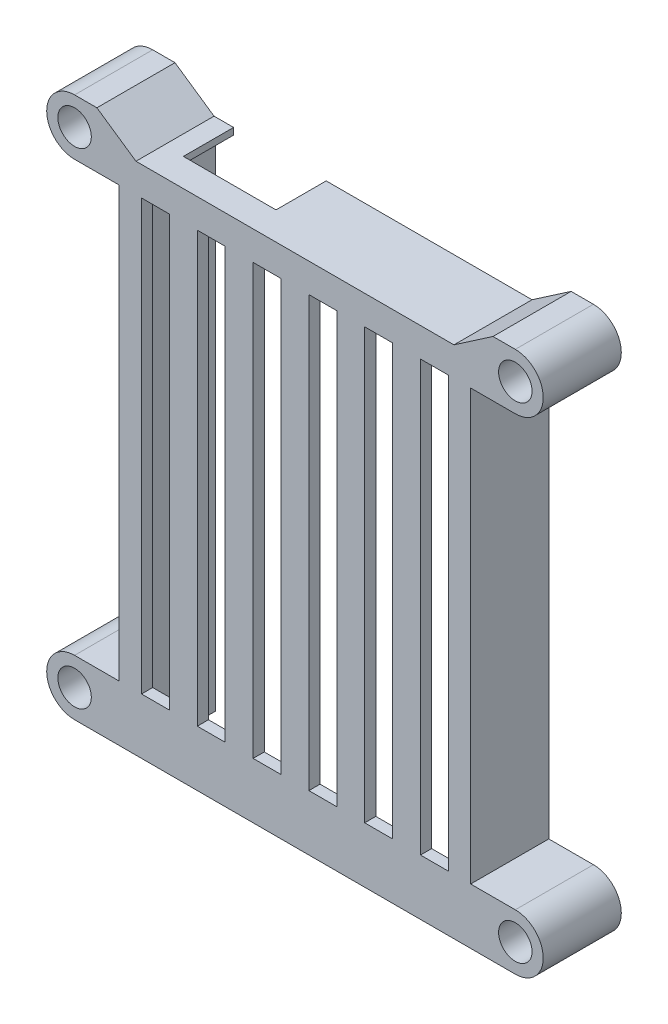
from build123d import *

# Parameters (mm, degrees)
EXTRUDE_1_DEPTH          = 2
EXTRUDE_2_DEPTH          = 12
SKETCH_5_R               = 3
CUT_EXTRUDE_1_DEPTH      = 15
SKETCH_8_W               = 16.6
SKETCH_8_H               = 9
CUT_EXTRUDE_3_DEPTH      = 7
CUT_EXTRUDE_5_DEPTH      = 1
CUT_EXTRUDE_5_DEPTH_BACK = 15
SKETCH_11_W              = 5
SKETCH_11_H              = 77
CUT_EXTRUDE_6_DEPTH      = 2


with BuildPart() as part:
    # 草图1 → 凸台-拉伸1 (new body)
    with BuildSketch(Plane.XY):
        with BuildLine():
            Line((0, 0), (8, 0))
            Line((8, 0), (8, 77))
            Line((8, 77), (0, 77))
            ThreePointArc((0, 77), (-5, 82), (0, 87))
            Line((0, 87), (79, 87))
            ThreePointArc((79, 87), (84, 82), (79, 77))
            Line((79, 77), (71, 77))
            Line((71, 77), (71, 0))
            Line((71, 0), (79, 0))
            ThreePointArc((79, 0), (84, -5), (79, -10))
            Line((79, -10), (71, -10))
            Line((71, -10), (8, -10))
            Line((8, -10), (0, -10))
            ThreePointArc((0, -10), (-5, -5), (0, 0))
        make_face()
    extrude(amount=EXTRUDE_1_DEPTH)

    # 草图4 → 凸台-拉伸2 (add)
    with BuildSketch(Plane(origin=(0, 0, 0), x_dir=(-1, 0, 0), z_dir=(0, 0, -1))):
        with BuildLine():
            Line((-11.3, 81), (-11.3, -10))
            Line((-11.3, -10), (0, -10))
            ThreePointArc((0, -10), (5, -5), (0, 0))
            Line((0, 0), (-8, 0))
            Line((-8, 0), (-8, 77))
            Line((-8, 77), (0, 77))
            ThreePointArc((0, 77), (5, 82), (0, 87))
            Line((0, 87), (-79, 87))
            ThreePointArc((-79, 87), (-84, 82), (-79, 77))
            Line((-79, 77), (-71, 77))
            Line((-71, 77), (-71, 0))
            Line((-71, 0), (-79, 0))
            ThreePointArc((-79, 0), (-84, -5), (-79, -10))
            Line((-79, -10), (-67.7, -10))
            Line((-67.7, -10), (-67.7, 81))
            Line((-67.7, 81), (-11.3, 81))
        make_face()
    extrude(amount=EXTRUDE_2_DEPTH)

    # 草图5 → 切除-拉伸1 (cut, through all)
    with BuildSketch(Plane.XY.offset(2)):
        with Locations((79, 82)):
            Circle(SKETCH_5_R)
        with Locations((0, 82)):
            Circle(SKETCH_5_R)
        with Locations((79, -5)):
            Circle(SKETCH_5_R)
        with Locations((0, -5)):
            Circle(SKETCH_5_R)
    extrude(amount=-CUT_EXTRUDE_1_DEPTH, mode=Mode.SUBTRACT)

    # 草图8 → 切除-拉伸3 (cut, through all)
    with BuildSketch(Plane.XZ.offset(-81)):
        with Locations((22.8, -7.5)):
            Rectangle(SKETCH_8_W, SKETCH_8_H)
    extrude(amount=-CUT_EXTRUDE_3_DEPTH, mode=Mode.SUBTRACT)

    # 草图10 → 切除-拉伸5 (cut, two sides)
    with BuildSketch(Plane(origin=(0, 0, -12), x_dir=(-1, 0, 0), z_dir=(0, 0, -1))) as cut_extrude_5_sk:
        Polygon((-290.643675891, 234.868702326), (-75.001818332, 87), (-68.001818332, 82.2), (-11, 82.2), (-4, 87), (211.641857559, 234.868702326), (211.641857559, 757.808713643), (-290.643675891, 757.808713643), align=None)
    extrude(amount=CUT_EXTRUDE_5_DEPTH, mode=Mode.SUBTRACT)
    extrude(cut_extrude_5_sk.sketch, amount=-CUT_EXTRUDE_5_DEPTH_BACK, mode=Mode.SUBTRACT)

    # 草图11 → 切除-拉伸6 (cut)
    with BuildSketch(Plane.XY.offset(2)):
        with Locations((14.5, 38.5)):
            Rectangle(SKETCH_11_W, SKETCH_11_H)
        with Locations((24.5, 38.5)):
            Rectangle(SKETCH_11_W, SKETCH_11_H)
        with Locations((34.5, 38.5)):
            Rectangle(SKETCH_11_W, SKETCH_11_H)
        with Locations((44.5, 38.5)):
            Rectangle(SKETCH_11_W, SKETCH_11_H)
        with Locations((54.5, 38.5)):
            Rectangle(SKETCH_11_W, SKETCH_11_H)
        with Locations((64.5, 38.5)):
            Rectangle(SKETCH_11_W, SKETCH_11_H)
    extrude(amount=-CUT_EXTRUDE_6_DEPTH, mode=Mode.SUBTRACT)


solid = part.part
